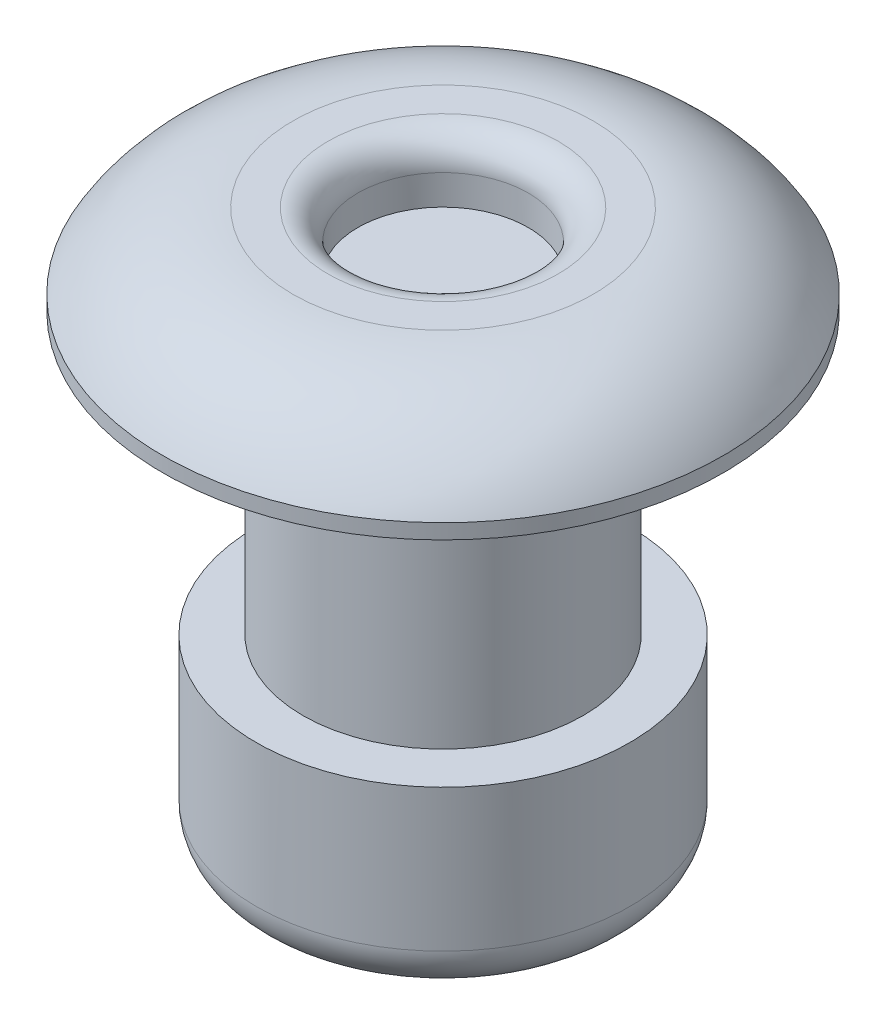
from build123d import *

# Parameters (mm, degrees)
SKETCH3_R          = 1.4478
CUT_EXTRUDE1_DEPTH = 1.016
FILLET1_R          = 0.508
FILLET3_R          = 0.762


with BuildPart() as part:
    # Sketch2 → Revolve1 (revolve)
    with BuildSketch(Plane.XY):
        with BuildLine():
            Line((0, 0), (-4.7625, 0))
            Line((-4.7625, 0), (-4.7625, 0.254))
            ThreePointArc((-4.7625, 0.254), (-3.827073968, 1.183884704), (-2.5527, 1.524))
            Line((-2.5527, 1.524), (0, 1.524))
            Line((0, 1.524), (0, 0))
        make_face()
    revolve(axis=Axis((0, -4.155418325, 0), (0, 1, 0)))

    # Sketch3 → Cut-Extrude1 (cut)
    with BuildSketch(Plane(origin=(0, 1.524, 0), x_dir=(1, 0, 0), z_dir=(0, 1, 0))):
        Circle(SKETCH3_R)
    extrude(amount=-CUT_EXTRUDE1_DEPTH, mode=Mode.SUBTRACT)

    # Fillet1
    fillet1_edges = [part.edges().sort_by_distance(p)[0] for p in [
        (-1.4478, 1.524, 0),
    ]]
    fillet(fillet1_edges, radius=FILLET1_R)

    # Sketch5 → Revolve3 (revolve)
    with BuildSketch(Plane.XY):
        Polygon((0, 0), (-2.38125, 0), (-2.38125, -4.7625), (-3.175, -4.7625), (-3.175, -7.9375), (-1.4478, -7.9375), (-1.4478, -5.3975), (0, -5.3975), align=None)
    revolve(axis=Axis((0, 0, 0), (0, 1, 0)))

    # Fillet3
    fillet3_edges = [part.edges().sort_by_distance(p)[0] for p in [
        (3.175, -7.9375, 0),
    ]]
    fillet(fillet3_edges, radius=FILLET3_R)


solid = part.part
